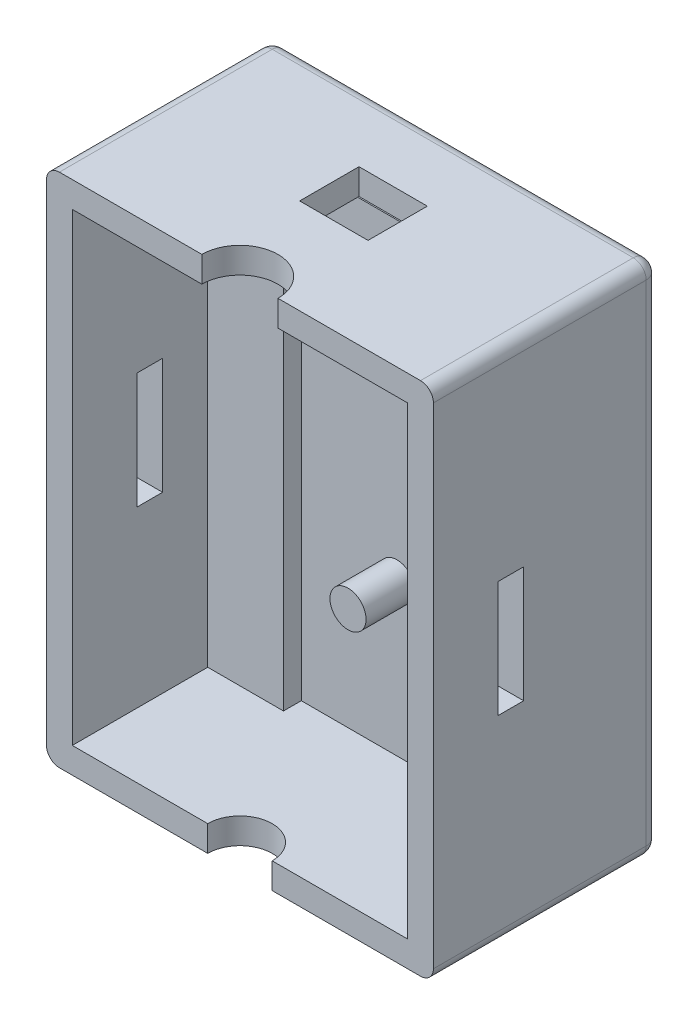
from build123d import *

# Parameters (mm, degrees)
SKETCH1_W               = 30
SKETCH1_H               = 40
BOSS_EXTRUDE1_DEPTH     = 17.5
SKETCH2_W               = 26
SKETCH2_H               = 36
CUT_EXTRUDE1_DEPTH      = 15.5
BOSS_EXTRUDE2_DEPTH     = 3.62
CUT_EXTRUDE5_DEPTH      = 29
CUT_EXTRUDE5_DEPTH_BACK = 3
CUT_EXTRUDE6_DEPTH      = 3
SKETCH13_W              = 5.875
SKETCH13_H              = 36
BOSS_EXTRUDE4_DEPTH     = 5
CUT_EXTRUDE7_REACH      = 42
CUT_EXTRUDE8_DEPTH      = 3
SKETCH16_R              = 1.4
BOSS_EXTRUDE5_DEPTH     = 3.8
FILLET1_R               = 1


with BuildPart() as part:
    # Sketch1 → Boss-Extrude1 (new body)
    with BuildSketch(Plane.XY):
        Rectangle(SKETCH1_W, SKETCH1_H)
    extrude(amount=BOSS_EXTRUDE1_DEPTH)

    # Sketch2 → Cut-Extrude1 (cut)
    with BuildSketch(Plane.XY.offset(17.5)):
        Rectangle(SKETCH2_W, SKETCH2_H)
    extrude(amount=-CUT_EXTRUDE1_DEPTH, mode=Mode.SUBTRACT)

    # Sketch6 → Boss-Extrude2 (add)
    with BuildSketch(Plane.XY.offset(2)):
        Polygon((7.125, 18), (0, 18), (-7.125, 18), (-7.125, -13), (-7.125, -18), (7.125, -18), (7.125, -13), align=None)
    extrude(amount=BOSS_EXTRUDE2_DEPTH)

    # Sketch10 → Cut-Extrude5 (cut, two sides)
    with BuildSketch(Plane.ZY.offset(-13)) as cut_extrude5_sk:
        Polygon((12.5, 0), (12.5, -4.5), (10.5, -4.5), (10.5, 0), (10.5, 4.5), (12.5, 4.5), align=None)
    extrude(amount=CUT_EXTRUDE5_DEPTH, mode=Mode.SUBTRACT)
    extrude(cut_extrude5_sk.sketch, amount=-CUT_EXTRUDE5_DEPTH_BACK, mode=Mode.SUBTRACT)

    # Sketch12 → Cut-Extrude6 (cut, through all)
    with BuildSketch(Plane(origin=(0, -18, 0), x_dir=(1, 0, 0), z_dir=(0, 1, 0))):
        with BuildLine():
            Line((2.5, -17.5), (-2.5, -17.5))
            ThreePointArc((-2.5, -17.5), (0, -15), (2.5, -17.5))
        make_face()
    extrude(amount=-CUT_EXTRUDE6_DEPTH, mode=Mode.SUBTRACT)

    # Sketch13 → Boss-Extrude4 (add)
    with BuildSketch(Plane.XY.offset(2)):
        with Locations((-10.0625, 0)):
            Rectangle(SKETCH13_W, SKETCH13_H)
        with Locations((10.0625, 0)):
            Rectangle(SKETCH13_W, SKETCH13_H)
    extrude(amount=BOSS_EXTRUDE4_DEPTH)

    # Sketch14 → Cut-Extrude7 (cut, up to next)
    with BuildSketch(Plane(origin=(0, 20, 0), x_dir=(1, 0, 0), z_dir=(0, 1, 0)), mode=Mode.PRIVATE) as cut_extrude7_sk1:
        with BuildLine():
            Line((2.95, -17.5), (-2.95, -17.5))
            ThreePointArc((-2.95, -17.5), (0, -14.55), (2.95, -17.5))
        make_face()
    cut_extrude7_tool1 = extrude(cut_extrude7_sk1.sketch, amount=-CUT_EXTRUDE7_REACH, mode=Mode.PRIVATE) & part.part
    add(cut_extrude7_tool1.solids().sort_by_distance((0, 20, 16.247981))[0], mode=Mode.SUBTRACT)

    # Sketch15 → Cut-Extrude8 (cut, through all)
    with BuildSketch(Plane.XZ.offset(-18)):
        Polygon((-2.75, 10.12), (-2.75, 5.52), (2.55, 5.52), (2.55, 7.82), (2.55, 10.12), align=None)
    extrude(amount=-CUT_EXTRUDE8_DEPTH, mode=Mode.SUBTRACT)

    # Sketch16 → Boss-Extrude5 (add)
    with BuildSketch(Plane.XY.offset(5.62)):
        with Locations((0.3, -6.225)):
            Circle(SKETCH16_R)
    extrude(amount=BOSS_EXTRUDE5_DEPTH)

    # Fillet1
    fillet1_edges = [part.edges().sort_by_distance(p)[0] for p in [
        (0, -20, 0),
        (-15, 0, 0),
        (0, 20, 0),
        (15, 0, 0),
        (15, -20, 8.75),
        (-15, -20, 8.75),
        (-15, 20, 8.75),
        (15, 20, 8.75),
    ]]
    fillet(fillet1_edges, radius=FILLET1_R)


solid = part.part
